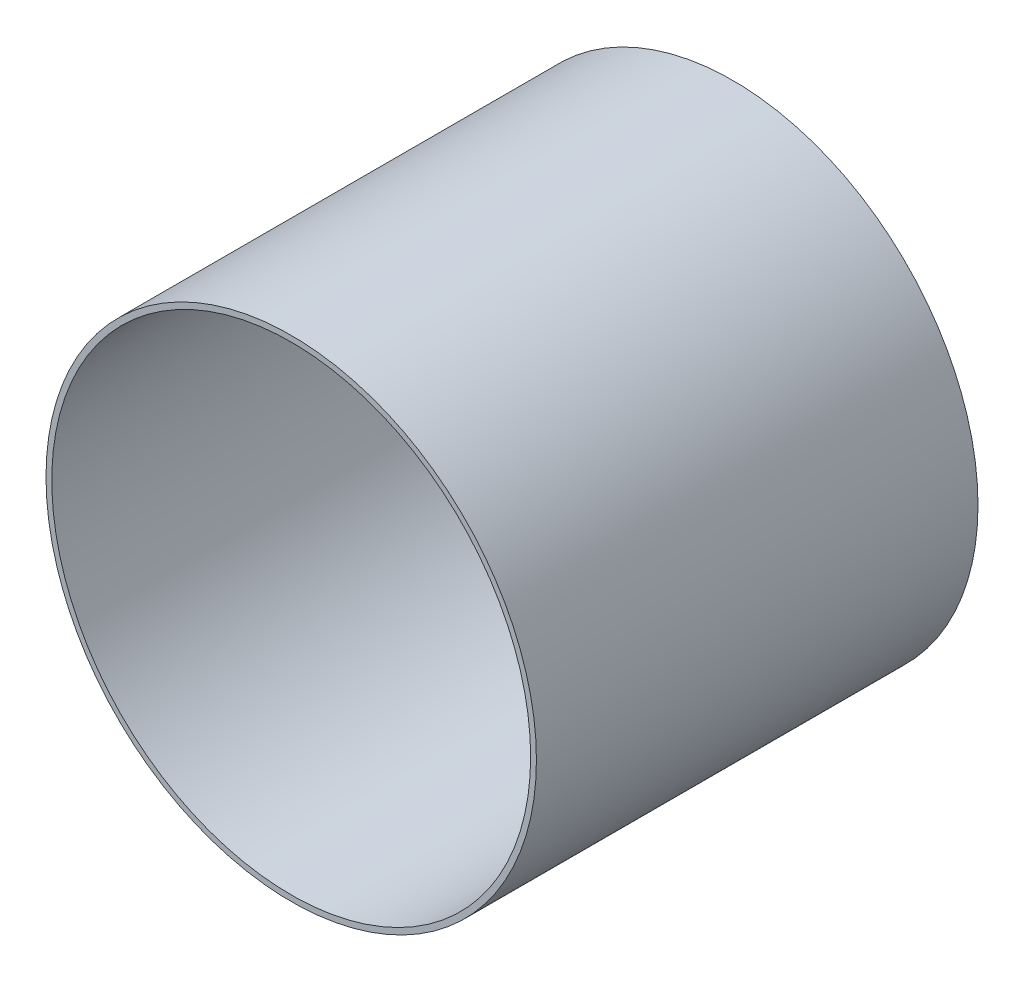
from build123d import *

# Parameters (mm, degrees)
SKETCH1_R           = 63.4746
SKETCH1_R_2         = 61.976
BOSS_EXTRUDE1_DEPTH = 57.15


with BuildPart() as part:
    # Sketch1 → Boss-Extrude1 (new body, symmetric)
    with BuildSketch(Plane.XY):
        Circle(SKETCH1_R)
        Circle(SKETCH1_R_2, mode=Mode.SUBTRACT)
    extrude(amount=BOSS_EXTRUDE1_DEPTH, both=True)


solid = part.part
